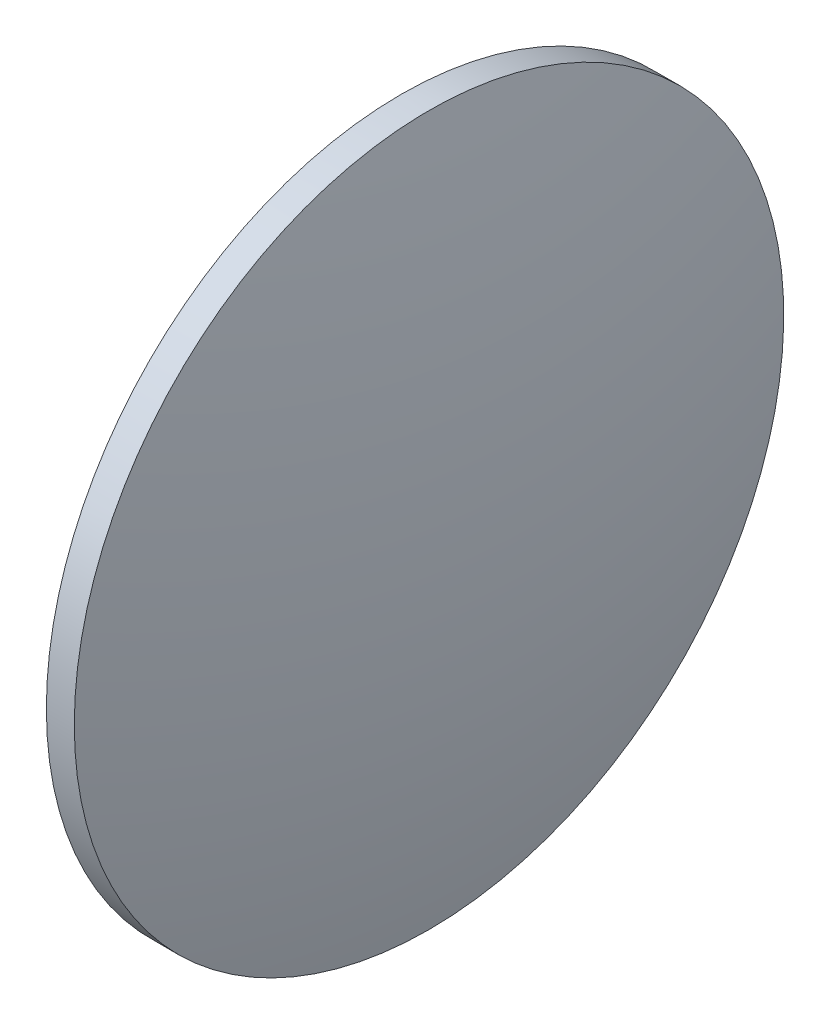
from build123d import *

# Parameters (mm, degrees)
SKETCH_1_ONE_SIDE_W = 0.999998
SKETCH_1_ONE_SIDE_H = 12.7


with BuildPart() as part:
    # 草图1 one side → 旋转1 (revolve)
    with BuildSketch(Plane.XY, mode=Mode.PRIVATE) as revolve_1_sk:
        with Locations((86.458193775, 54.966113023)):
            Rectangle(SKETCH_1_ONE_SIDE_W, SKETCH_1_ONE_SIDE_H)
        with BuildLine():
            Line((84.478227489, 48.616113023), (85.958194775, 48.616113023))
            Line((85.958194775, 48.616113023), (85.958194775, 61.316113023))
            ThreePointArc((85.958194775, 61.316113023), (84.849466967, 55.009083834), (84.478227489, 48.616113023))
        make_face()
        with BuildLine():
            Line((86.958192775, 48.616113023), (88.43816006, 48.616113023))
            ThreePointArc((88.43816006, 48.616113023), (88.066920583, 55.009083834), (86.958192775, 61.316113023))
            Line((86.958192775, 61.316113023), (86.958192775, 48.616113023))
        make_face()
    revolve(revolve_1_sk.sketch.rotate(Axis((79.305401351, 48.616113023, 0), (1, 0, 0)), 90), axis=Axis((79.305401351, 48.616113023, 0), (1, 0, 0)))  # turned: the seam where the file's is


solid = part.part
